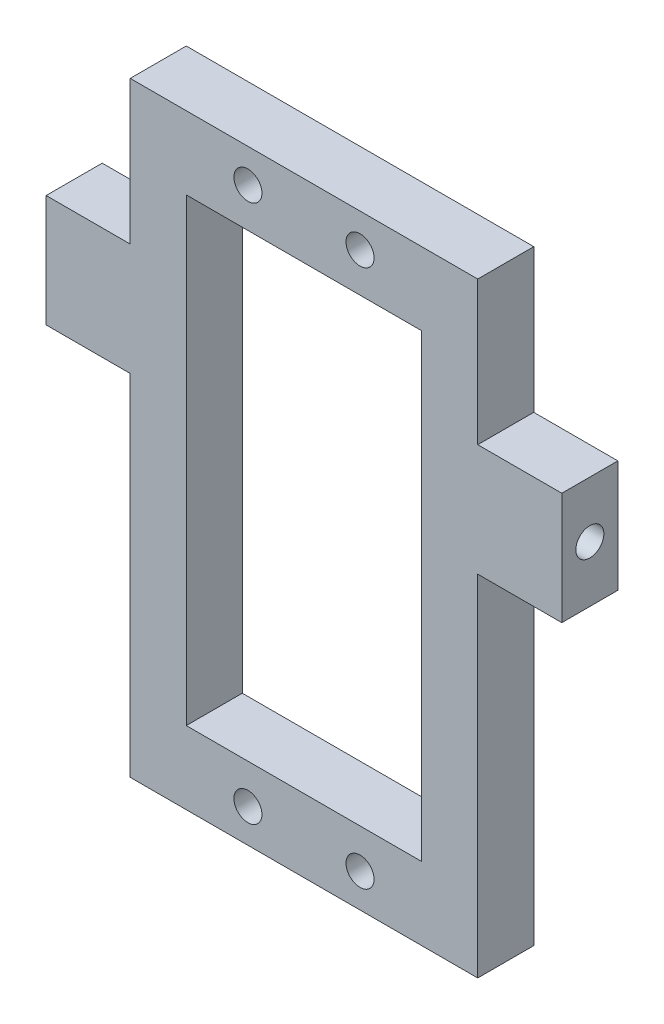
from build123d import *

# Parameters (mm, degrees)
SKETCH_1_W         = 31
SKETCH_1_H         = 54
SKETCH_1_W_2       = 21
SKETCH_1_H_2       = 41
EXTRUDE_1_DEPTH    = 5
SKETCH_2_W         = 5
SKETCH_2_H         = 10
EXTRUDE_2_DEPTH    = 7.5
HOLE_WIZARD_M3_1_D = 2.5


with BuildPart() as part:
    # 草图1 → 凸台-拉伸1 (new body)
    with BuildSketch(Plane.XY):
        Rectangle(SKETCH_1_W, SKETCH_1_H)
        Rectangle(SKETCH_1_W_2, SKETCH_1_H_2, mode=Mode.SUBTRACT)
    extrude(amount=EXTRUDE_1_DEPTH)

    # 草图2 → 凸台-拉伸2 (add)
    with BuildSketch(Plane(origin=(15.5, 0, 0), x_dir=(0, 0, -1), z_dir=(1, 0, 0))):
        with Locations((-2.5, 9.2)):
            Rectangle(SKETCH_2_W, SKETCH_2_H)
    extrude_2 = extrude(amount=EXTRUDE_2_DEPTH)

    # 镜向1: 凸台-拉伸2 across plane
    add(extrude_2.mirror(Plane(origin=(0, 0, 0), x_dir=(0, 0, 1), z_dir=(1, 0, 0))))

    # M3 螺纹孔1 (through all)
    with Locations(Plane(origin=(0, 0, 0), x_dir=(-1, 0, 0), z_dir=(0, 0, -1))):
        with Locations((-5, -24), (5, -24), (-5, 24), (5, 24)):
            Hole(HOLE_WIZARD_M3_1_D / 2)

    # 草图7 → M3 螺纹孔2 (revolve, cut)
    with BuildSketch(Plane(origin=(23, 9.2, 2.5), x_dir=(0, 0, -1), z_dir=(0, 1, 0))):
        Polygon((0, 0), (0, 6.251075774), (1.25, 5.5), (1.25, 0), align=None)
    hole_wizard_m3_2 = revolve(axis=Axis((29.35, 9.2, 2.5), (-1, 0, 0)), mode=Mode.SUBTRACT)

    # 镜向2: M3 螺纹孔2 across plane
    add(hole_wizard_m3_2.mirror(Plane(origin=(0, 0, 0), x_dir=(0, 0, 1), z_dir=(1, 0, 0))), mode=Mode.SUBTRACT)


solid = part.part
